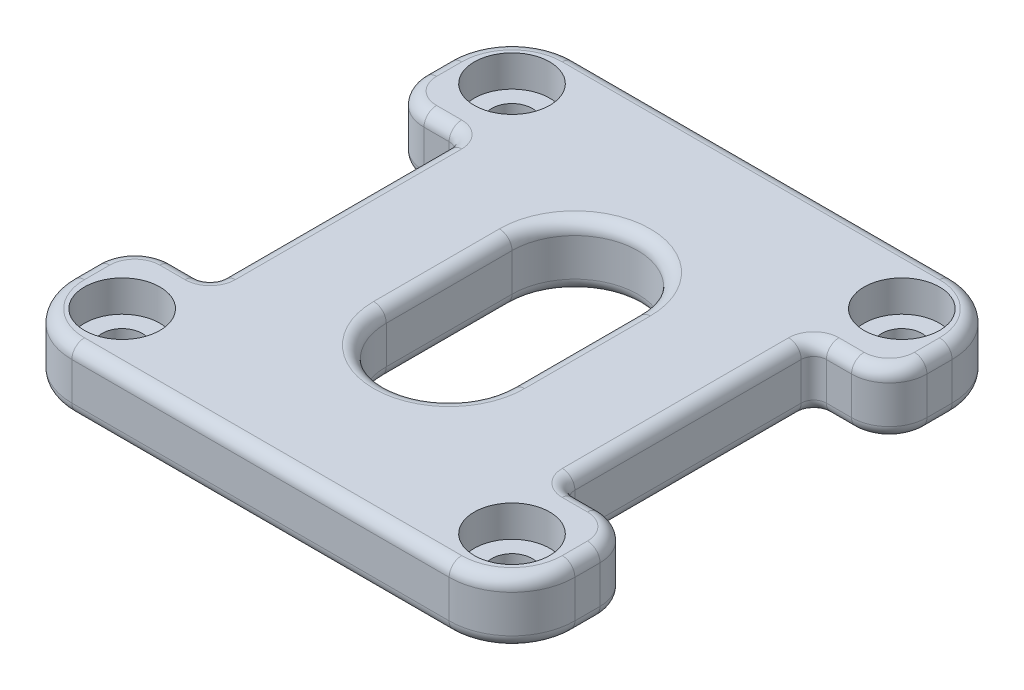
from build123d import *

# Parameters (mm, degrees)
SKETCH_1_W          = 40
SKETCH_1_H          = 40
EXTRUDE_1_DEPTH     = 5
SKETCH_2_R          = 1.6
CUT_EXTRUDE_1_DEPTH = 6
FILLET_1_R          = 5
SKETCH_3_W          = 10
SKETCH_3_H          = 20
CUT_EXTRUDE_2_DEPTH = 6
FILLET_2_R          = 1
FILLET_3_R          = 3
SKETCH_4_R          = 3
CUT_EXTRUDE_3_DEPTH = 2.5
FILLET_5_R          = 1
CUT_EXTRUDE_4_DEPTH = 6
FILLET_6_R          = 1


with BuildPart() as part:
    # 草图1 → 凸台-拉伸1 (new body)
    with BuildSketch(Plane(origin=(0, 0, 0), x_dir=(1, 0, 0), z_dir=(0, 1, 0))):
        Rectangle(SKETCH_1_W, SKETCH_1_H)
    extrude(amount=EXTRUDE_1_DEPTH)

    # 草图2 → 切除-拉伸1 (cut, through all)
    with BuildSketch(Plane(origin=(0, 5, 0), x_dir=(1, 0, 0), z_dir=(0, 1, 0))):
        with Locations((-15.5, 15.5)):
            Circle(SKETCH_2_R)
        with Locations((15.5, 15.5)):
            Circle(SKETCH_2_R)
        with Locations((15.5, -15.5)):
            Circle(SKETCH_2_R)
        with Locations((-15.5, -15.5)):
            Circle(SKETCH_2_R)
    extrude(amount=-CUT_EXTRUDE_1_DEPTH, mode=Mode.SUBTRACT)

    # 圆角1
    fillet_1_edges = [part.edges().sort_by_distance(p)[0] for p in [
        (20, 2.5, 20),
        (-20, 2.5, 20),
        (-20, 2.5, -20),
        (20, 2.5, -20),
    ]]
    fillet(fillet_1_edges, radius=FILLET_1_R)

    # 草图3 → 切除-拉伸2 (cut, through all)
    with BuildSketch(Plane(origin=(0, 5, 0), x_dir=(1, 0, 0), z_dir=(0, 1, 0))):
        with Locations((-19, 0)):
            Rectangle(SKETCH_3_W, SKETCH_3_H)
        with Locations((19, 0)):
            Rectangle(SKETCH_3_W, SKETCH_3_H)
    extrude(amount=-CUT_EXTRUDE_2_DEPTH, mode=Mode.SUBTRACT)

    # 圆角2
    fillet_2_edges = [part.edges().sort_by_distance(p)[0] for p in [
        (-14, 2.5, 10),
        (-14, 2.5, -10),
        (14, 2.5, -10),
        (14, 2.5, 10),
    ]]
    fillet(fillet_2_edges, radius=FILLET_2_R)

    # 圆角3
    fillet_3_edges = [part.edges().sort_by_distance(p)[0] for p in [
        (-20, 2.5, 10),
        (-20, 2.5, -10),
        (20, 2.5, -10),
        (20, 2.5, 10),
    ]]
    fillet(fillet_3_edges, radius=FILLET_3_R)

    # 草图4 → 切除-拉伸3 (cut)
    with BuildSketch(Plane(origin=(0, 5, 0), x_dir=(1, 0, 0), z_dir=(0, 1, 0))):
        with Locations((-15.5, 15.5)):
            Circle(SKETCH_4_R)
        with Locations((15.5, 15.5)):
            Circle(SKETCH_4_R)
        with Locations((15.5, -15.5)):
            Circle(SKETCH_4_R)
        with Locations((-15.5, -15.5)):
            Circle(SKETCH_4_R)
    extrude(amount=-CUT_EXTRUDE_3_DEPTH, mode=Mode.SUBTRACT)

    # 圆角5
    fillet_5_edges = [part.edges().sort_by_distance(p)[0] for p in [
        (14, 5, 0),
        (14, 0, 0),
        (16, 0, -10),
        (16, 0, 10),
        (16, 5, 10),
        (-14, 5, 0),
        (-14, 0, 0),
        (-16, 0, 10),
        (-16, 0, -10),
        (-16, 5, -10),
        (14.292893219, 5, -9.707106781),
        (14.292893219, 0, -9.707106781),
        (14.292893219, 5, 9.707106781),
        (14.292893219, 0, 9.707106781),
        (-14.292893219, 5, 9.707106781),
        (-14.292893219, 0, 9.707106781),
        (-14.292893219, 5, -9.707106781),
        (-14.292893219, 0, -9.707106781),
        (-16, 5, 10),
        (-20, 5, 14),
        (16, 5, -10),
        (20, 5, -14),
        (-19.121320344, 5, -10.878679656),
        (-19.121320344, 5, 10.878679656),
        (19.121320344, 5, -10.878679656),
        (19.121320344, 5, 10.878679656),
        (20, 0, -14),
        (-20, 0, 14),
        (-19.121320344, 0, -10.878679656),
        (-19.121320344, 0, 10.878679656),
        (19.121320344, 0, -10.878679656),
        (19.121320344, 0, 10.878679656),
        (20, 0, 14),
        (20, 5, 14),
        (0, 0, 20),
        (-20, 0, -14),
        (0, 0, -20),
        (-18.535533906, 0, -18.535533906),
        (18.535533906, 0, -18.535533906),
        (-18.535533906, 0, 18.535533906),
        (18.535533906, 0, 18.535533906),
        (0, 5, 20),
        (0, 5, -20),
        (-20, 5, -14),
        (-18.535533906, 5, -18.535533906),
        (18.535533906, 5, -18.535533906),
        (-18.535533906, 5, 18.535533906),
        (18.535533906, 5, 18.535533906),
    ]]
    fillet(fillet_5_edges, radius=FILLET_5_R)

    # 草图5 → 切除-拉伸4 (cut, through all)
    with BuildSketch(Plane(origin=(0, 5, 0), x_dir=(1, 0, 0), z_dir=(0, 1, 0))):
        with BuildLine():
            Line((-5, -5), (-5, 5))
            ThreePointArc((-5, 5), (0, 10), (5, 5))
            Line((5, 5), (5, -5))
            ThreePointArc((5, -5), (0, -10), (-5, -5))
        make_face()
    extrude(amount=-CUT_EXTRUDE_4_DEPTH, mode=Mode.SUBTRACT)

    # 圆角6
    fillet_6_edges = [part.edges().sort_by_distance(p)[0] for p in [
        (0, 0, 10),
        (-5, 0, 0),
        (0, 0, -10),
        (5, 0, 0),
        (0, 5, 10),
        (5, 5, 0),
        (0, 5, -10),
        (-5, 5, 0),
    ]]
    fillet(fillet_6_edges, radius=FILLET_6_R)


solid = part.part
